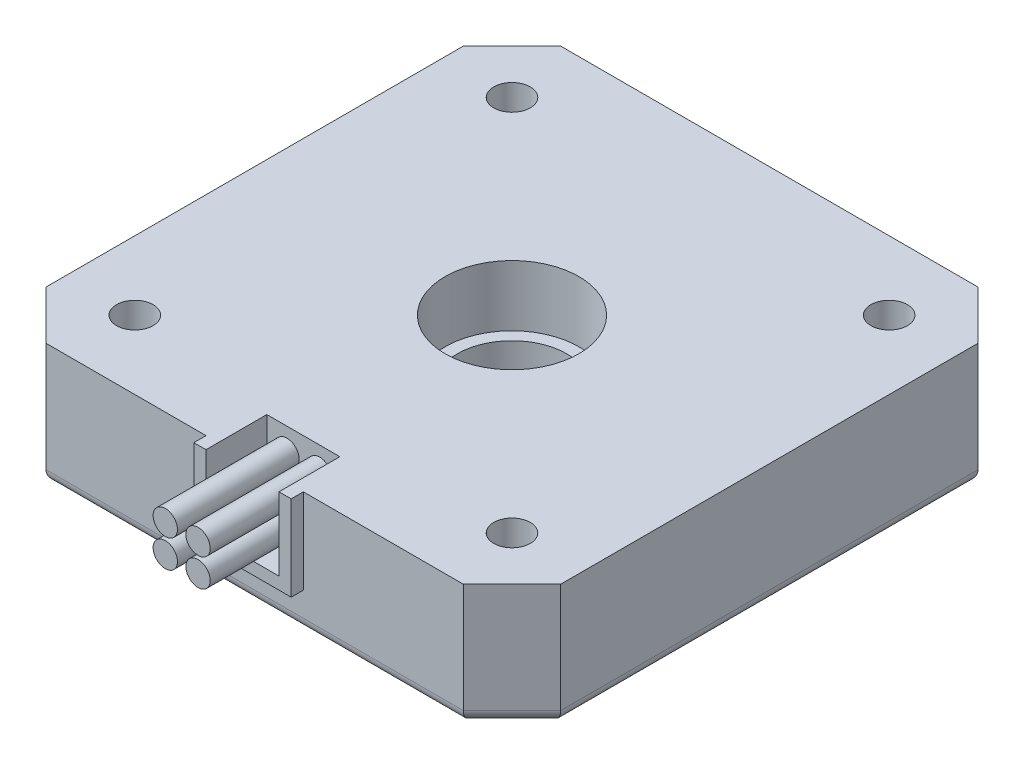
from build123d import *

# Parameters (mm, degrees)
BOSS_EXTRUDE1_DEPTH = 10
SKETCH2_R           = 1.5
CUT_EXTRUDE1_DEPTH  = 10
SKETCH3_R           = 3.1
CUT_EXTRUDE2_DEPTH  = 3
FILLET1_R           = 0.5
SKETCH4_R           = 4.5
CUT_EXTRUDE3_DEPTH  = 10
FILLET2_R           = 0.5
SKETCH5_R           = 5.5
CUT_EXTRUDE4_DEPTH  = 5
FILLET3_R           = 1
SKETCH6_W           = 8
SKETCH6_H           = 7
BOSS_EXTRUDE2_DEPTH = 1
SKETCH7_W           = 6
SKETCH7_H           = 6
CUT_EXTRUDE5_DEPTH  = 5
SKETCH8_R           = 1
BOSS_EXTRUDE4_DEPTH = 10


with BuildPart() as part:
    # Sketch1 → Boss-Extrude1 (new body)
    with BuildSketch(Plane(origin=(0, 0, 0), x_dir=(1, 0, 0), z_dir=(0, 1, 0))):
        Polygon((-21.15, 17.15), (-17.15, 21.15), (17.15, 21.15), (21.15, 17.15), (21.15, -17.15), (17.15, -21.15), (-17.15, -21.15), (-21.15, -17.15), align=None)
    extrude(amount=BOSS_EXTRUDE1_DEPTH)

    # Sketch2 → Cut-Extrude1 (cut)
    with BuildSketch(Plane.XZ):
        with Locations((-15.5, 15.5)):
            Circle(SKETCH2_R)
        with Locations((15.5, 15.5)):
            Circle(SKETCH2_R)
        with Locations((15.5, -15.5)):
            Circle(SKETCH2_R)
        with Locations((-15.5, -15.5)):
            Circle(SKETCH2_R)
    extrude(amount=-CUT_EXTRUDE1_DEPTH, mode=Mode.SUBTRACT)

    # Sketch3 → Cut-Extrude2 (cut)
    with BuildSketch(Plane.XZ):
        with Locations((-15.5, 15.5)):
            Circle(SKETCH3_R)
        with Locations((15.5, 15.5)):
            Circle(SKETCH3_R)
        with Locations((15.5, -15.5)):
            Circle(SKETCH3_R)
        with Locations((-15.5, -15.5)):
            Circle(SKETCH3_R)
    extrude(amount=-CUT_EXTRUDE2_DEPTH, mode=Mode.SUBTRACT)

    # Fillet1
    fillet1_edges = [part.edges().sort_by_distance(p)[0] for p in [
        (-18.6, 0, -15.5),
        (-18.6, 3, -15.5),
        (12.4, 0, -15.5),
        (12.4, 3, -15.5),
        (12.4, 0, 15.5),
        (12.4, 3, 15.5),
        (-18.6, 0, 15.5),
        (-18.6, 3, 15.5),
    ]]
    fillet(fillet1_edges, radius=FILLET1_R)

    # Sketch4 → Cut-Extrude3 (cut)
    with BuildSketch(Plane.XZ):
        Circle(SKETCH4_R)
    extrude(amount=-CUT_EXTRUDE3_DEPTH, mode=Mode.SUBTRACT)

    # Fillet2
    fillet2_edges = [part.edges().sort_by_distance(p)[0] for p in [
        (-4.5, 0, 0),
    ]]
    fillet(fillet2_edges, radius=FILLET2_R)

    # Sketch5 → Cut-Extrude4 (cut)
    with BuildSketch(Plane(origin=(0, 10, 0), x_dir=(1, 0, 0), z_dir=(0, 1, 0))):
        Circle(SKETCH5_R)
    extrude(amount=-CUT_EXTRUDE4_DEPTH, mode=Mode.SUBTRACT)

    # Fillet3
    fillet3_edges = [part.edges().sort_by_distance(p)[0] for p in [
        (-19.15, 0, -19.15),
        (0, 0, -21.15),
        (19.15, 0, -19.15),
        (21.15, 0, 0),
        (19.15, 0, 19.15),
        (0, 0, 21.15),
        (-19.15, 0, 19.15),
        (-21.15, 0, 0),
    ]]
    fillet(fillet3_edges, radius=FILLET3_R)

    # Sketch6 → Boss-Extrude2 (add)
    with BuildSketch(Plane.XY.offset(21.15)):
        with Locations((0, 6.5)):
            Rectangle(SKETCH6_W, SKETCH6_H)
    extrude(amount=BOSS_EXTRUDE2_DEPTH)

    # Sketch7 → Cut-Extrude5 (cut)
    with BuildSketch(Plane.XY.offset(22.15)):
        with Locations((0, 7)):
            Rectangle(SKETCH7_W, SKETCH7_H)
    extrude(amount=-CUT_EXTRUDE5_DEPTH, mode=Mode.SUBTRACT)

    # Sketch8 → Boss-Extrude4 (add)
    with BuildSketch(Plane.XY.offset(17.15)):
        with Locations((-1.347255874, 5.854684621)):
            Circle(SKETCH8_R)
        with Locations((1.347255874, 5.854684621)):
            Circle(SKETCH8_R)
        with Locations((1.347255874, 8.145315379)):
            Circle(SKETCH8_R)
        with Locations((-1.347255874, 8.145315379)):
            Circle(SKETCH8_R)
    extrude(amount=BOSS_EXTRUDE4_DEPTH)


solid = part.part
